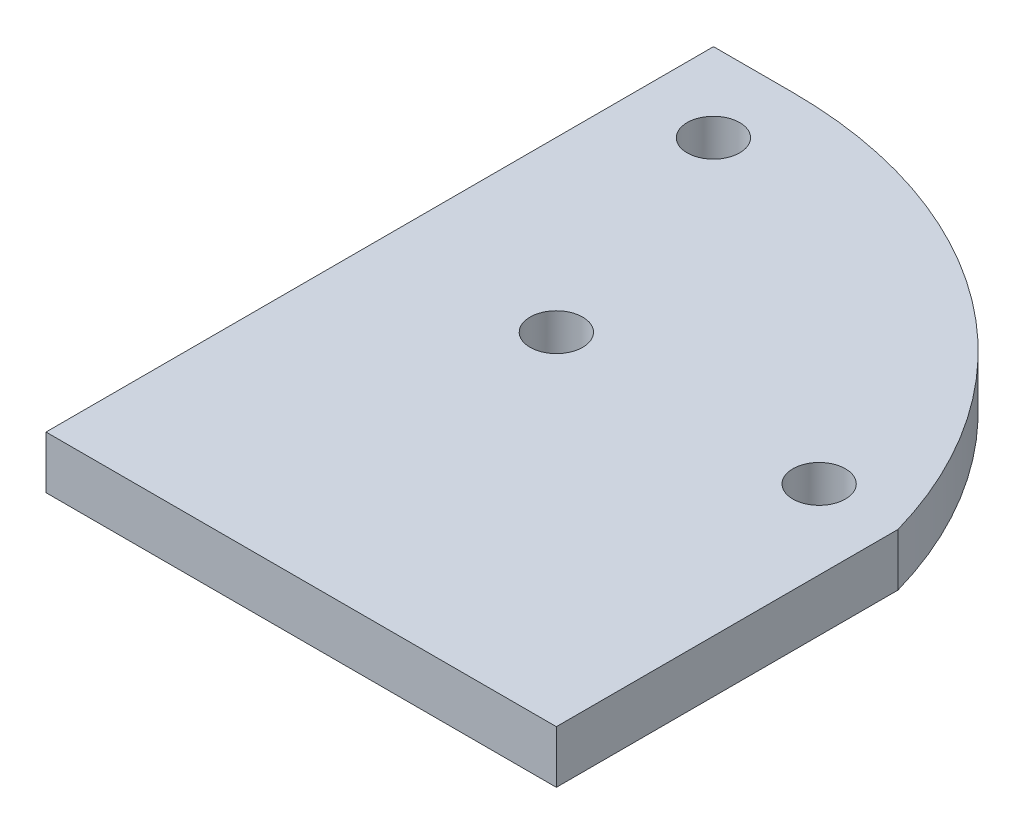
from build123d import *

# Parameters (mm, degrees)
BOSS_EXTRUDE1_DEPTH     = 10
SKETCH2_R               = 5
CUT_EXTRUDE4_DEPTH      = 11
CUT_EXTRUDE4_DEPTH_BACK = 1


with BuildPart() as part:
    # Sketch1 → Boss-Extrude1 (new body)
    with BuildSketch(Plane(origin=(0, 0, 0), x_dir=(1, 0, 0), z_dir=(0, 1, 0))):
        with BuildLine():
            Line((0, 0), (0, 127))
            Line((0, 127), (15, 127))
            ThreePointArc((15, 127), (66.440280909, 109.758742946), (97.1, 65))
            Line((97.1, 65), (97.1, 0))
            Line((97.1, 0), (0, 0))
        make_face()
    extrude(amount=BOSS_EXTRUDE1_DEPTH)

    # Sketch2 → Cut-Extrude4 (cut, two sides)
    with BuildSketch(Plane(origin=(0, 0, 0), x_dir=(1, 0, 0), z_dir=(0, 1, 0))) as cut_extrude4_sk:
        with Locations((14.998992834, 111.984631039)):
            Circle(SKETCH2_R)
        with Locations((82.1, 65)):
            Circle(SKETCH2_R)
        with Locations((32.1, 65)):
            Circle(SKETCH2_R)
    extrude(amount=CUT_EXTRUDE4_DEPTH, mode=Mode.SUBTRACT)
    extrude(cut_extrude4_sk.sketch, amount=-CUT_EXTRUDE4_DEPTH_BACK, mode=Mode.SUBTRACT)


solid = part.part
